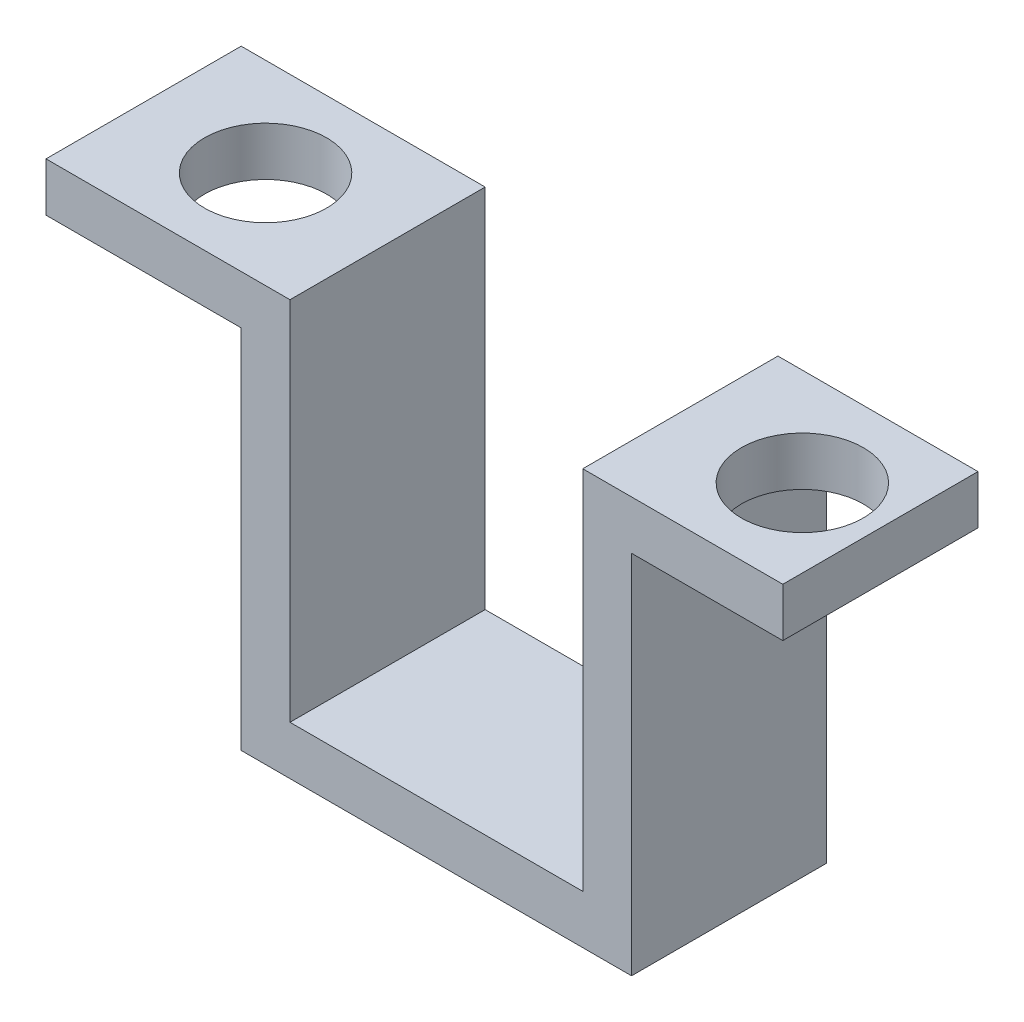
from build123d import *

# Parameters (mm, degrees)
CROQUIS1_W              = 8
CROQUIS1_H              = 2
SALIENTE_EXTRUIR1_DEPTH = 8
CROQUIS2_R              = 2.5
CORTAR_EXTRUIR1_DEPTH   = 2
SKETCH1_W               = 8
SKETCH1_H               = 2
CUT_EXTRUDE1_DEPTH      = 1.8


with BuildPart() as part:
    # Croquis1 → Saliente-Extruir1 (new body)
    with BuildSketch(Plane.XY):
        with Locations((-12, 6.5)):
            Rectangle(CROQUIS1_W, CROQUIS1_H)
        Polygon((-6, 7.5), (-8, 7.5), (-8, 5.5), (-8, -9.5), (8, -9.5), (8, 5.5), (8, 7.5), (6, 7.5), (6, -7.5), (-6, -7.5), align=None)
        with Locations((12, 6.5)):
            Rectangle(CROQUIS1_W, CROQUIS1_H)
    extrude(amount=SALIENTE_EXTRUIR1_DEPTH)

    # Croquis2 → Cortar-Extruir1 (cut)
    with BuildSketch(Plane(origin=(0, 7.5, 0), x_dir=(1, 0, 0), z_dir=(0, 1, 0))):
        with Locations((-11, -4)):
            Circle(CROQUIS2_R)
        with Locations((11, -4)):
            Circle(CROQUIS2_R)
    extrude(amount=-CORTAR_EXTRUIR1_DEPTH, mode=Mode.SUBTRACT)

    # Sketch1 → Cut-Extrude1 (cut)
    with BuildSketch(Plane(origin=(16, 0, 0), x_dir=(0, 0, -1), z_dir=(1, 0, 0))):
        with Locations((-4, 6.5)):
            Rectangle(SKETCH1_W, SKETCH1_H)
    extrude(amount=-CUT_EXTRUDE1_DEPTH, mode=Mode.SUBTRACT)


solid = part.part
